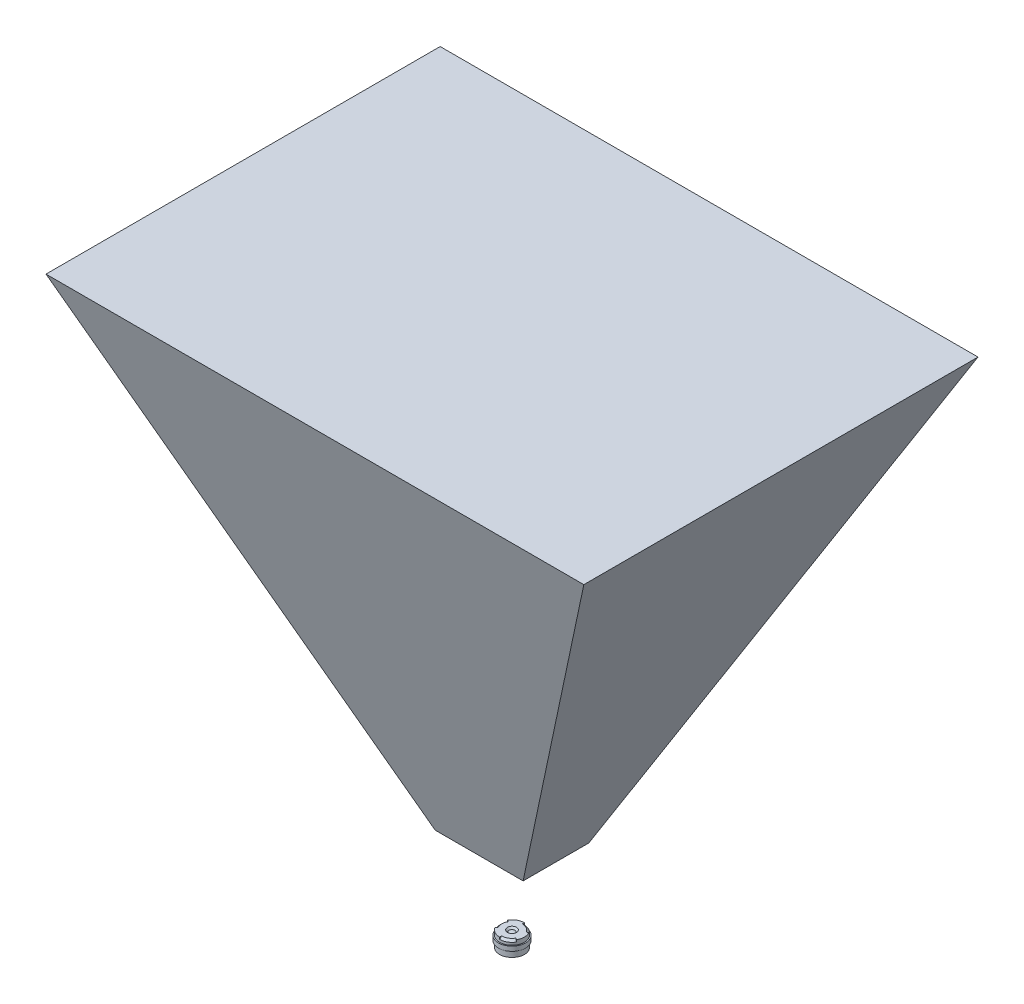
from build123d import *

# Parameters (mm, degrees)
SKIZZE4_W             = 0.25
SKIZZE4_H             = 1
TOOLFACE_ANGLE        = 60
KREISMUSTER1_COUNT    = 3
FOV_3_6MM_F_2_9_DEPTH = 100
SKIZZE8_OUTSIDE_W     = 251.934
SKIZZE8_OUTSIDE_H     = 173.192
SKIZZE8_OUTSIDE_R     = 5
FOV2_DEPTH            = 44.676428112
FOV2_DEPTH_BACK       = 44.676428112


with BuildPart() as part:
    # Skizze3 → Body (revolve)
    with BuildSketch(Plane.XY):
        with BuildLine():
            Line((1, 0.8), (2.75, 0.8))
            Line((2.75, 0.8), (2.75, -2.55))
            Line((2.75, -2.55), (2.1, -2.55))
            Line((2.1, -2.55), (1.8, -2.25))
            ThreePointArc((1.8, -2.25), (0.91241438, -2.474486277), (0, -2.55))
            Line((0, -2.55), (0, 0.525))
            ThreePointArc((0, 0.525), (0.316474723, 0.499842016), (0.625, 0.425))
            Line((0.625, 0.425), (1, 0.8))
        make_face()
    revolve(axis=Axis((0, 0, 0), (0, -1, 0)))

    # Skizze4 → Thread (revolve)
    with BuildSketch(Plane.XY):
        with Locations((2.875, -0.7)):
            Rectangle(SKIZZE4_W, SKIZZE4_H)
    revolve(axis=Axis((0, 0, 0), (0, 1, 0)))

    # Skizze5 → Toolface (revolve, cut)
    with BuildSketch(Plane(origin=(0, 0, 0), x_dir=(0, 0, -1), z_dir=(1, 0, 0))):
        Polygon((2.75, 0.8), (2.75, 0.35), (2.3, 0.8), align=None)
    toolface = revolve(axis=Axis((0, 0, 0), (0, -1, 0)), revolution_arc=TOOLFACE_ANGLE, mode=Mode.SUBTRACT)

    # Kreismuster1: Toolface ×3 about axis
    kreismuster1_axis = Axis((0, 0, 0), (0, 1, 0))
    for i in range(1, KREISMUSTER1_COUNT):
        add(toolface.rotate(kreismuster1_axis, i * 360 / KREISMUSTER1_COUNT), mode=Mode.SUBTRACT)


with BuildPart() as body_2:
    # Skizze6 → FOV - 3,6mm f/2,9 (new body, symmetric)
    with BuildSketch(Plane(origin=(0, 0, 0), x_dir=(0, 0, -1), z_dir=(1, 0, 0))):
        Polygon((-7.279404685, 18.707826613), (-43.676428112, 118.707826613), (43.676428112, 118.707826613), (7.279404685, 18.707826613), align=None)
    extrude(amount=FOV_3_6MM_F_2_9_DEPTH, both=True)

    # Skizze8 outside → FOV2 (cut, two sides)
    with BuildSketch(Plane.XY) as fov2_sk:
        with Locations((0, 58.079)):
            Rectangle(SKIZZE8_OUTSIDE_W, SKIZZE8_OUTSIDE_H)
        Circle(SKIZZE8_OUTSIDE_R, mode=Mode.SUBTRACT)
        Polygon((-9.740481092, 18.707826613), (-59.598641898, 118.707826613), (59.598641898, 118.707826613), (9.740481092, 18.707826613), align=None, mode=Mode.SUBTRACT)
    extrude(amount=FOV2_DEPTH, mode=Mode.SUBTRACT)
    extrude(fov2_sk.sketch, amount=-FOV2_DEPTH_BACK, mode=Mode.SUBTRACT)


solid = Compound([part.part, body_2.part])
